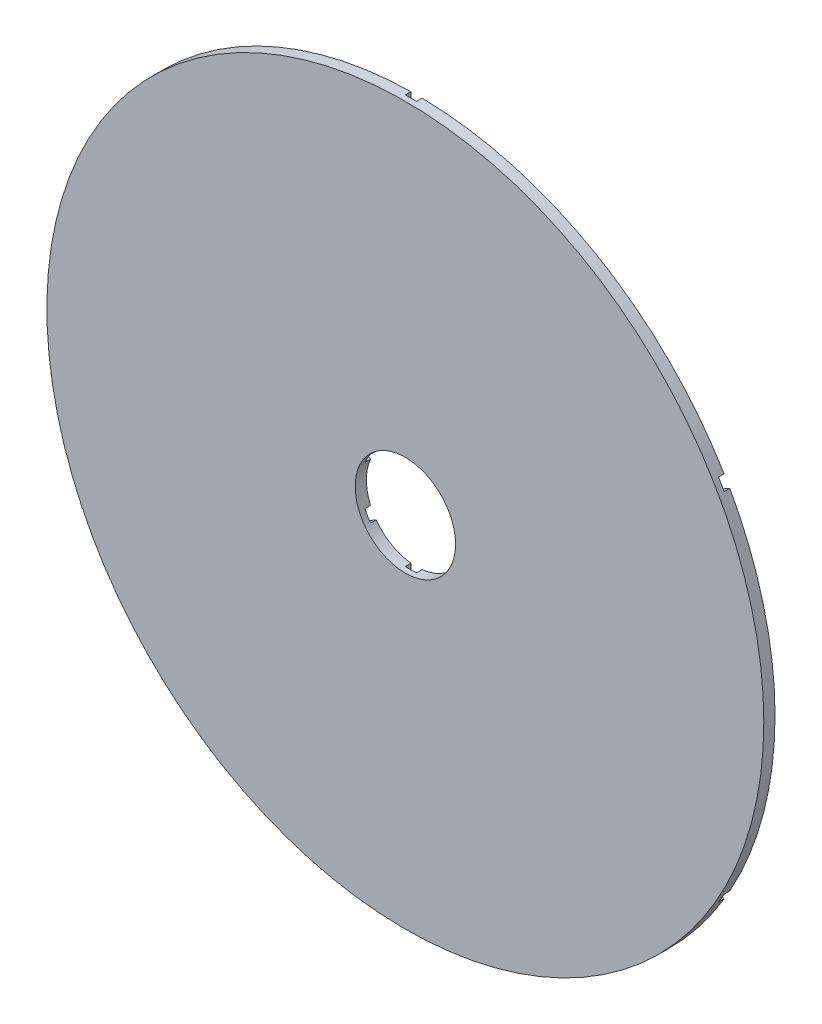
from build123d import *

# Parameters (mm, degrees)
SKETCH1_R           = 101.6
BOSS_EXTRUDE1_DEPTH = 3.175
CUT_EXTRUDE3_DEPTH  = 1.5875
SKETCH3_R           = 14.224
CUT_EXTRUDE4_DEPTH  = 4.175


with BuildPart() as part:
    # Sketch1 → Boss-Extrude1 (new body)
    with BuildSketch(Plane.XY):
        Circle(SKETCH1_R)
    extrude(amount=BOSS_EXTRUDE1_DEPTH)

    # Sketch2 → Cut-Extrude3 (cut)
    with BuildSketch(Plane(origin=(0, 0, 0), x_dir=(-1, 0, 0), z_dir=(0, 0, -1))):
        with BuildLine():
            ThreePointArc((-88.771189624, -49.418983121), (-87.988181024, -50.8), (-87.183689624, -52.168613778))
            Line((-87.183689624, -52.168613778), (-1.5875, -2.749630657))
            Line((-1.5875, -2.749630657), (-1.5875, -0.916543552))
            Line((-1.5875, -0.916543552), (-3.175, 0))
            Line((-3.175, 0), (-88.771189624, -49.418983121))
        make_face()
        Polygon((-1.5875, -0.916543552), (-1.5875, -2.749630657), (0, -1.833087105), align=None)
        Polygon((-1.5875, -0.916543552), (0, -1.833087105), (1.5875, -0.916543552), (1.5875, 0.916543552), (0, 1.833087105), (-1.5875, 0.916543552), align=None)
        Polygon((1.5875, -0.916543552), (0, -1.833087105), (1.5875, -2.749630657), align=None)
        Polygon((-3.175, 0), (-1.5875, -0.916543552), (-1.5875, 0.916543552), align=None)
        Polygon((-1.5875, 2.749630657), (-1.5875, 0.916543552), (0, 1.833087105), align=None)
        Polygon((0, 1.833087105), (1.5875, 0.916543552), (1.5875, 2.749630657), align=None)
        Polygon((1.5875, 0.916543552), (1.5875, -0.916543552), (3.175, 0), align=None)
        with BuildLine():
            Line((1.5875, 0.916543552), (3.175, 0))
            Line((3.175, 0), (88.771189624, 49.418983121))
            ThreePointArc((88.771189624, 49.418983121), (87.988181024, 50.8), (87.183689624, 52.168613778))
            Line((87.183689624, 52.168613778), (1.5875, 2.749630657))
            Line((1.5875, 2.749630657), (1.5875, 0.916543552))
        make_face()
        with BuildLine():
            Line((3.175, 0), (1.5875, -0.916543552))
            Line((1.5875, -0.916543552), (1.5875, -2.749630657))
            Line((1.5875, -2.749630657), (87.183689624, -52.168613778))
            ThreePointArc((87.183689624, -52.168613778), (87.988181024, -50.8), (88.771189624, -49.418983121))
            Line((88.771189624, -49.418983121), (3.175, 0))
        make_face()
        with BuildLine():
            Line((-1.5875, 2.749630657), (0, 1.833087105))
            Line((0, 1.833087105), (1.5875, 2.749630657))
            Line((1.5875, 2.749630657), (1.5875, 101.587596899))
            ThreePointArc((1.5875, 101.587596899), (0, 101.6), (-1.5875, 101.587596899))
            Line((-1.5875, 101.587596899), (-1.5875, 2.749630657))
        make_face()
        with BuildLine():
            Line((-88.771189624, 49.418983121), (-3.175, 0))
            Line((-3.175, 0), (-1.5875, 0.916543552))
            Line((-1.5875, 0.916543552), (-1.5875, 2.749630657))
            Line((-1.5875, 2.749630657), (-87.183689624, 52.168613778))
            ThreePointArc((-87.183689624, 52.168613778), (-87.988181024, 50.8), (-88.771189624, 49.418983121))
        make_face()
        with BuildLine():
            Line((0, -1.833087105), (-1.5875, -2.749630657))
            Line((-1.5875, -2.749630657), (-1.5875, -101.587596899))
            ThreePointArc((-1.5875, -101.587596899), (0, -101.6), (1.5875, -101.587596899))
            Line((1.5875, -101.587596899), (1.5875, -2.749630657))
            Line((1.5875, -2.749630657), (0, -1.833087105))
        make_face()
    extrude(amount=-CUT_EXTRUDE3_DEPTH, mode=Mode.SUBTRACT)

    # Sketch3 → Cut-Extrude4 (cut, through all)
    with BuildSketch(Plane.XY.offset(3.175)):
        Circle(SKETCH3_R)
    extrude(amount=-CUT_EXTRUDE4_DEPTH, mode=Mode.SUBTRACT)


solid = part.part
